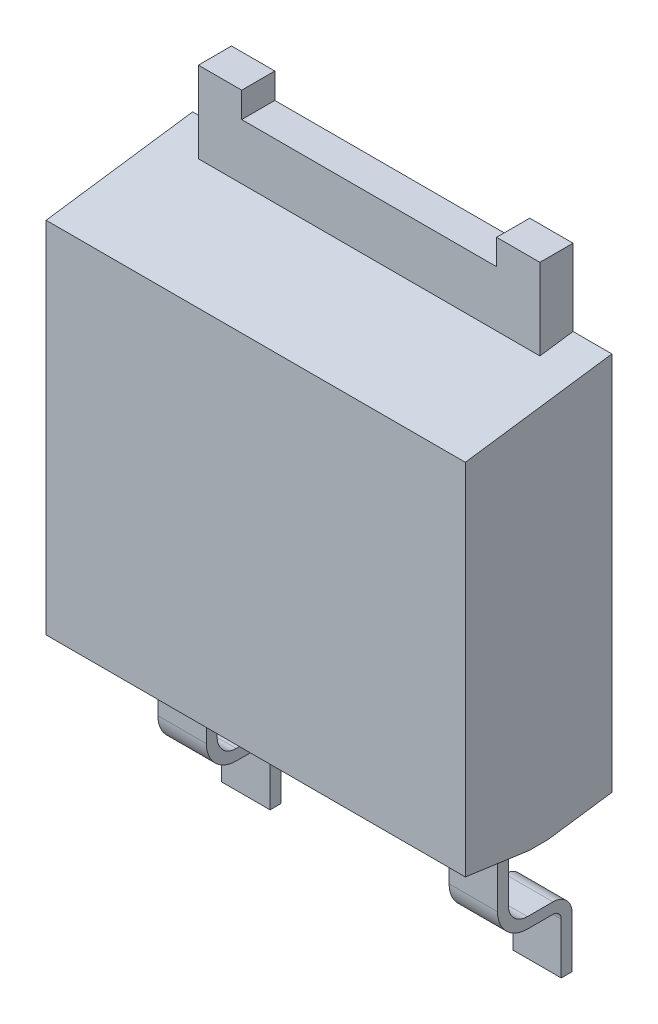
from build123d import *

# Parameters (mm, degrees)
SKETCH1_W           = 6.58
SKETCH1_H           = 6.1
BOSS_EXTRUDE1_DEPTH = 2.3
DRAFT1_ANGLE        = -8
CHAMFER1_SIZE       = 1
CHAMFER1_SIZE2      = 0.140540835
BOSS_EXTRUDE2_DEPTH = 0.52
EXTRUDE_THIN1_DEPTH = 0.38
SKETCH4_W           = 0.17
SKETCH4_H           = 0.83
EXTRUDE_THIN2_DEPTH = 0.38


with BuildPart() as part:
    # Sketch1 → Boss-Extrude1 (new body)
    with BuildSketch(Plane.XY):
        with Locations((3.29, 3.05)):
            Rectangle(SKETCH1_W, SKETCH1_H)
    extrude(amount=BOSS_EXTRUDE1_DEPTH)

    # Draft1
    draft1_faces = [part.faces().sort_by_distance(p)[0] for p in [
        (3.29, 6.1, 1.15),
    ]]
    draft(draft1_faces, Plane(origin=(0, 0, 0), x_dir=(-1, 0, 0), z_dir=(0, 0, -1)), DRAFT1_ANGLE)

    # Chamfer1
    chamfer1_edges = [part.edges().sort_by_distance(p)[0] for p in [
        (3.29, 0, 0),
        (3.29, 0, 2.3),
    ]]
    chamfer1_side = [part.faces().sort_by_distance(p)[0] for p in [
        (3.29, 0, 1.15),
    ]]
    chamfer(chamfer1_edges, length=CHAMFER1_SIZE, length2=CHAMFER1_SIZE2, reference=chamfer1_side[0])

    # Sketch2 → Boss-Extrude2 (add)
    with BuildSketch(Plane.XY):
        Polygon((0.61, 5.77675608), (5.97, 5.77675608), (5.97, 6.1), (5.97, 7.3), (5.29, 7.3), (5.29, 6.9), (1.29, 6.9), (1.29, 7.3), (0.61, 7.3), (0.61, 6.1), align=None)
    extrude(amount=BOSS_EXTRUDE2_DEPTH)

    # Sketch3 → Extrude-Thin1 (add, symmetric)
    with BuildSketch(Plane(origin=(5.575, 0, 0), x_dir=(0, 0, -1), z_dir=(1, 0, 0))):
        with BuildLine():
            Line((-1, 0), (-1, -1.21))
            ThreePointArc((-1, -1.21), (-0.912132034, -1.422132034), (-0.7, -1.51))
            Line((-0.7, -1.51), (-0.3, -1.51))
            ThreePointArc((-0.3, -1.51), (-0.087867966, -1.597867966), (0, -1.81))
            Line((0, -1.81), (0, -2.61))
            Line((0, -2.61), (-0.17, -2.61))
            Line((-0.17, -2.61), (-0.17, -1.81))
            ThreePointArc((-0.17, -1.81), (-0.208076118, -1.718076118), (-0.3, -1.68))
            Line((-0.3, -1.68), (-0.7, -1.68))
            ThreePointArc((-0.7, -1.68), (-1.032340187, -1.542340187), (-1.17, -1.21))
            Line((-1.17, -1.21), (-1.17, 0))
            Line((-1.17, 0), (-1, 0))
        make_face()
    extrude_thin1 = extrude(amount=EXTRUDE_THIN1_DEPTH, both=True)

    # Mirror1: Extrude-Thin1 across plane
    add(extrude_thin1.mirror(Plane(origin=(3.29, 0, 0), x_dir=(0, 0, 1), z_dir=(1, 0, 0))))

    # Sketch4 → Extrude-Thin2 (add, symmetric)
    with BuildSketch(Plane(origin=(3.29, 0, 0), x_dir=(0, 0, -1), z_dir=(1, 0, 0))):
        with Locations((-1.085, -0.415)):
            Rectangle(SKETCH4_W, SKETCH4_H)
    extrude(amount=EXTRUDE_THIN2_DEPTH, both=True)


solid = part.part
